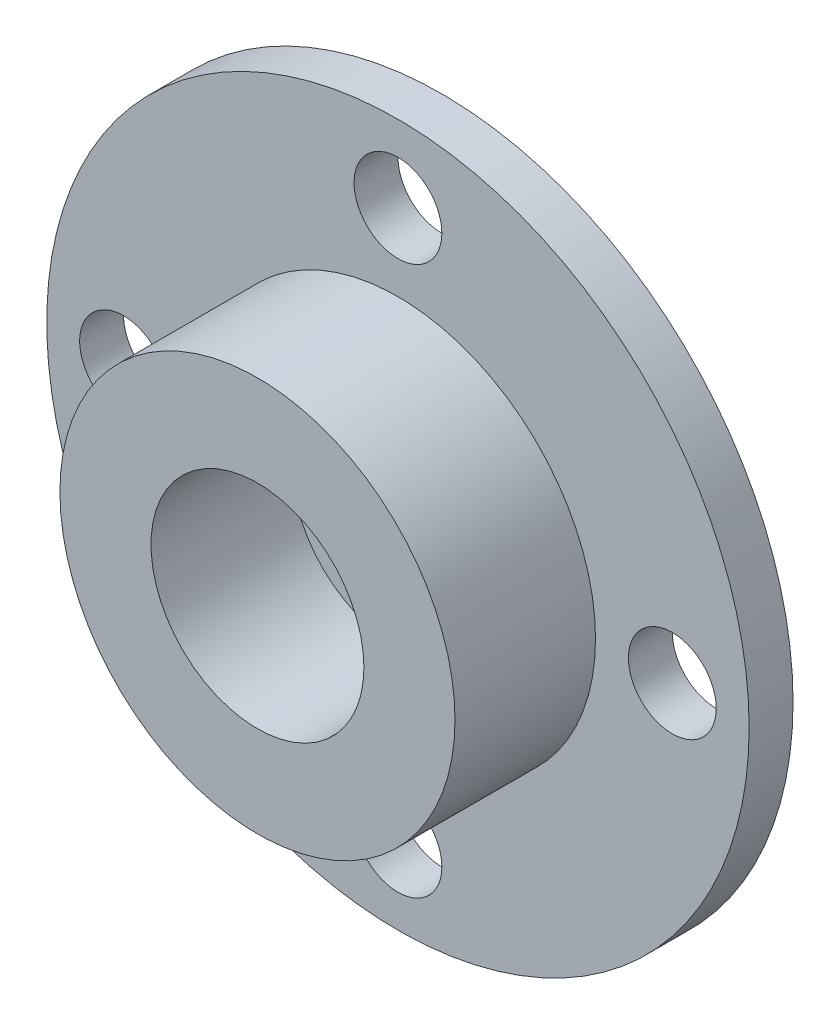
from build123d import *

# Parameters (mm, degrees)
SKETCH1_R           = 4.5
SKETCH1_R_2         = 2.425
BOSS_EXTRUDE1_DEPTH = 3.2
SKETCH1_3_R         = 8
SKETCH1_3_R_2       = 1
BOSS_EXTRUDE2_DEPTH = 1
SKETCH2_R           = 3
SKETCH2_R_2         = 2
BOSS_EXTRUDE3_DEPTH = 1


with BuildPart() as part:
    # Sketch1 → Boss-Extrude1 (new body)
    with BuildSketch(Plane.XY):
        Circle(SKETCH1_R)
        Circle(SKETCH1_R_2, mode=Mode.SUBTRACT)
    extrude(amount=BOSS_EXTRUDE1_DEPTH)

    # Sketch1_3 → Boss-Extrude2 (add)
    with BuildSketch(Plane.XY):
        Circle(SKETCH1_3_R)
        Circle(SKETCH1_3_R_2, mode=Mode.SUBTRACT)
        with Locations((0, -6.25)):
            Circle(SKETCH1_3_R_2, mode=Mode.SUBTRACT)
        with Locations((-6.25, 0)):
            Circle(SKETCH1_3_R_2, mode=Mode.SUBTRACT)
        with Locations((0, 6.25)):
            Circle(SKETCH1_3_R_2, mode=Mode.SUBTRACT)
        with Locations((6.25, 0)):
            Circle(SKETCH1_3_R_2, mode=Mode.SUBTRACT)
    extrude(amount=-BOSS_EXTRUDE2_DEPTH)

    # Sketch2 → Boss-Extrude3 (add)
    with BuildSketch(Plane(origin=(0, 0, -1), x_dir=(-1, 0, 0), z_dir=(0, 0, -1))):
        Circle(SKETCH2_R)
        Circle(SKETCH2_R_2, mode=Mode.SUBTRACT)
    extrude(amount=BOSS_EXTRUDE3_DEPTH)


solid = part.part
